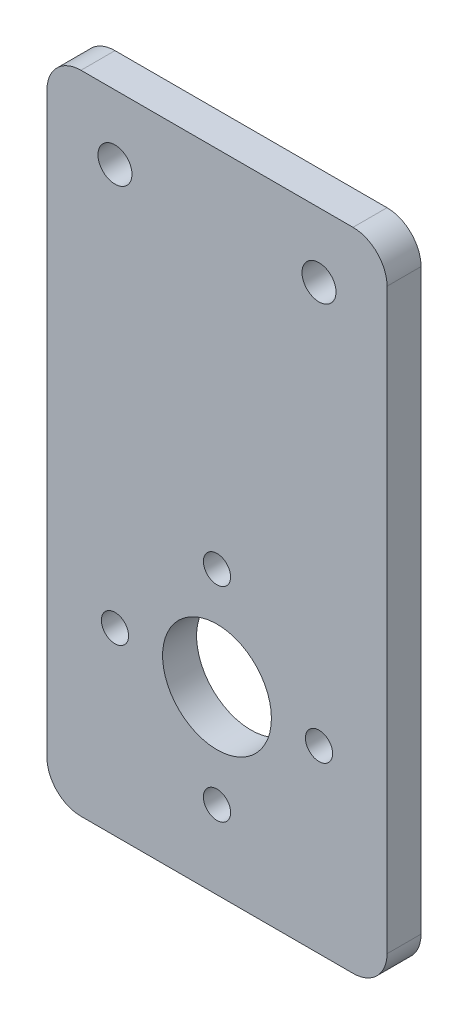
from build123d import *

# Parameters (mm, degrees)
SKETCH1_W           = 50
SKETCH1_H           = 95
SKETCH1_R           = 2.5
SKETCH1_R_2         = 8
SKETCH1_R_3         = 2
BOSS_EXTRUDE1_DEPTH = 5
FILLET1_R           = 5


with BuildPart() as part:
    # Sketch1 → Boss-Extrude1 (new body)
    with BuildSketch(Plane.XY):
        with Locations((25, -47.5)):
            Rectangle(SKETCH1_W, SKETCH1_H)
        with Locations((10, -9.5)):
            Circle(SKETCH1_R, mode=Mode.SUBTRACT)
        with Locations((40, -9.5)):
            Circle(SKETCH1_R, mode=Mode.SUBTRACT)
        with Locations((25, -68.525)):
            Circle(SKETCH1_R_2, mode=Mode.SUBTRACT)
        with Locations((25, -53.525)):
            Circle(SKETCH1_R_3, mode=Mode.SUBTRACT)
        with Locations((40, -68.525)):
            Circle(SKETCH1_R_3, mode=Mode.SUBTRACT)
        with Locations((25, -83.525)):
            Circle(SKETCH1_R_3, mode=Mode.SUBTRACT)
        with Locations((10, -68.525)):
            Circle(SKETCH1_R_3, mode=Mode.SUBTRACT)
    extrude(amount=BOSS_EXTRUDE1_DEPTH)

    # Fillet1
    fillet1_edges = [part.edges().sort_by_distance(p)[0] for p in [
        (0, 0, 2.5),
        (50, 0, 2.5),
        (50, -95, 2.5),
        (0, -95, 2.5),
    ]]
    fillet(fillet1_edges, radius=FILLET1_R)


solid = part.part
